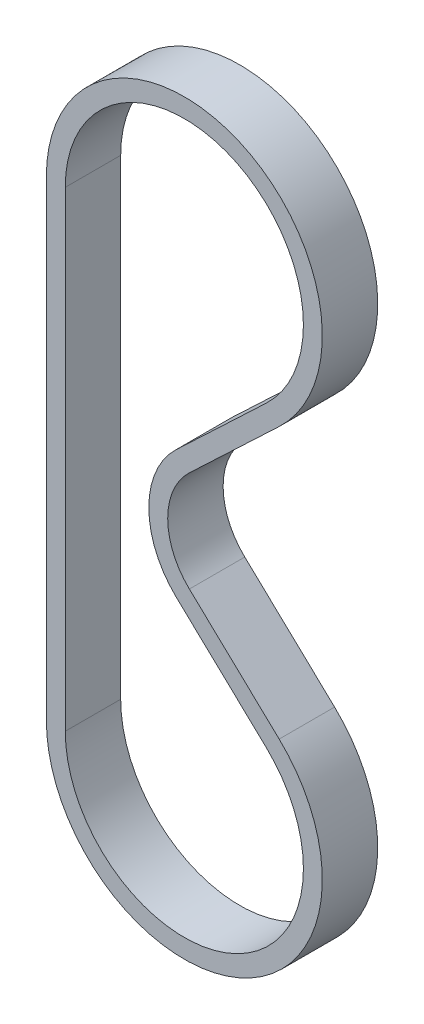
from build123d import *

# Parameters (mm, degrees)
EXTRUDE_1_DEPTH = 10


with BuildPart() as part:
    # ｽｹｯﾁ1 → 押し出し-薄板1 (new body)
    with BuildSketch(Plane.XY):
        with BuildLine():
            Line((0.906621718, 51.577656619), (17.114572187, 66.920939077))
            ThreePointArc((17.114572187, 66.920939077), (9.841080998, 107.867316191), (-24.895, 85))
            Line((-24.895, 85), (-24.895, 0))
            ThreePointArc((-24.895, 0), (9.841080998, -22.867316191), (17.114572187, 18.079060923))
            Line((17.114572187, 18.079060923), (0.906621718, 33.422343381))
            ThreePointArc((0.906621718, 33.422343381), (-3, 42.5), (0.906621718, 51.577656619))
        make_face()
        with BuildLine():
            Line((-1.437651878, 54.054041345), (14.770298592, 69.397323803))
            ThreePointArc((14.770298592, 69.397323803), (8.493096013, 104.735058782), (-21.485, 85))
            Line((-21.485, 85), (-21.485, 0))
            ThreePointArc((-21.485, 0), (8.493096013, -19.735058782), (14.770298592, 15.602676197))
            Line((14.770298592, 15.602676197), (-1.437651878, 30.945958655))
            ThreePointArc((-1.437651878, 30.945958655), (-6.41, 42.5), (-1.437651878, 54.054041345))
        make_face(mode=Mode.SUBTRACT)
    extrude(amount=EXTRUDE_1_DEPTH)


solid = part.part
